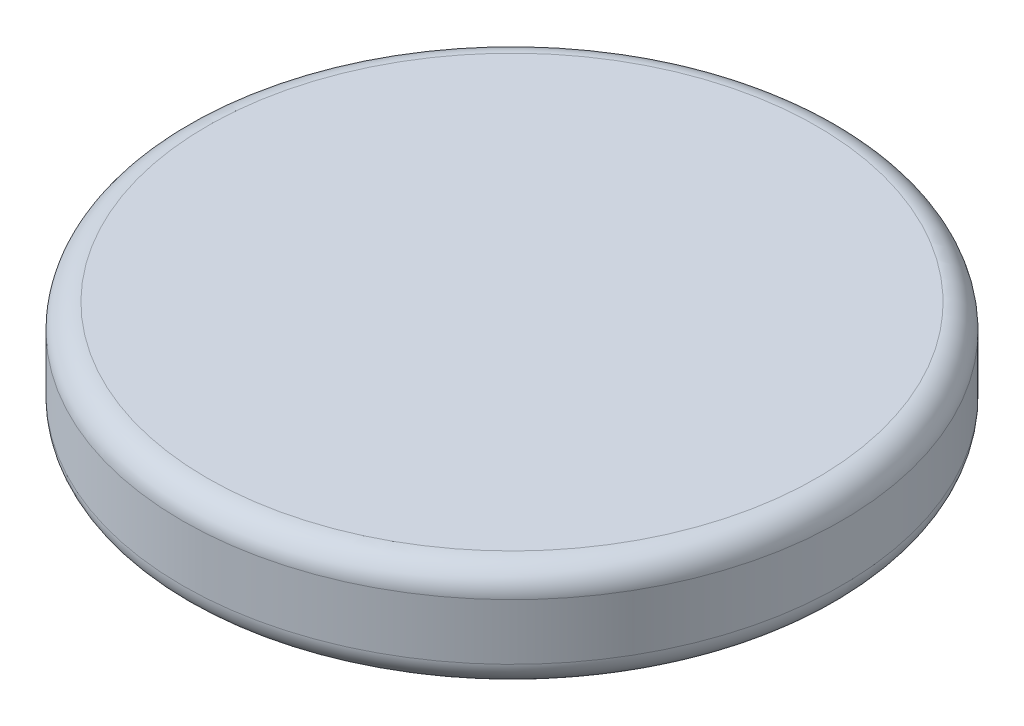
from build123d import *

# Parameters (mm, degrees)
SKETCH2_R           = 10
BOSS_EXTRUDE1_DEPTH = 3.2
FILLET1_R           = 0.75


with BuildPart() as part:
    # Sketch2 → Boss-Extrude1 (new body)
    with BuildSketch(Plane(origin=(0, 0, 0), x_dir=(1, 0, 0), z_dir=(0, 1, 0))):
        Circle(SKETCH2_R)
    extrude(amount=BOSS_EXTRUDE1_DEPTH)

    # Fillet1
    fillet1_edges = [part.edges().sort_by_distance(p)[0] for p in [
        (-10, 0, 0),
        (-10, 3.2, 0),
    ]]
    fillet(fillet1_edges, radius=FILLET1_R)


solid = part.part
